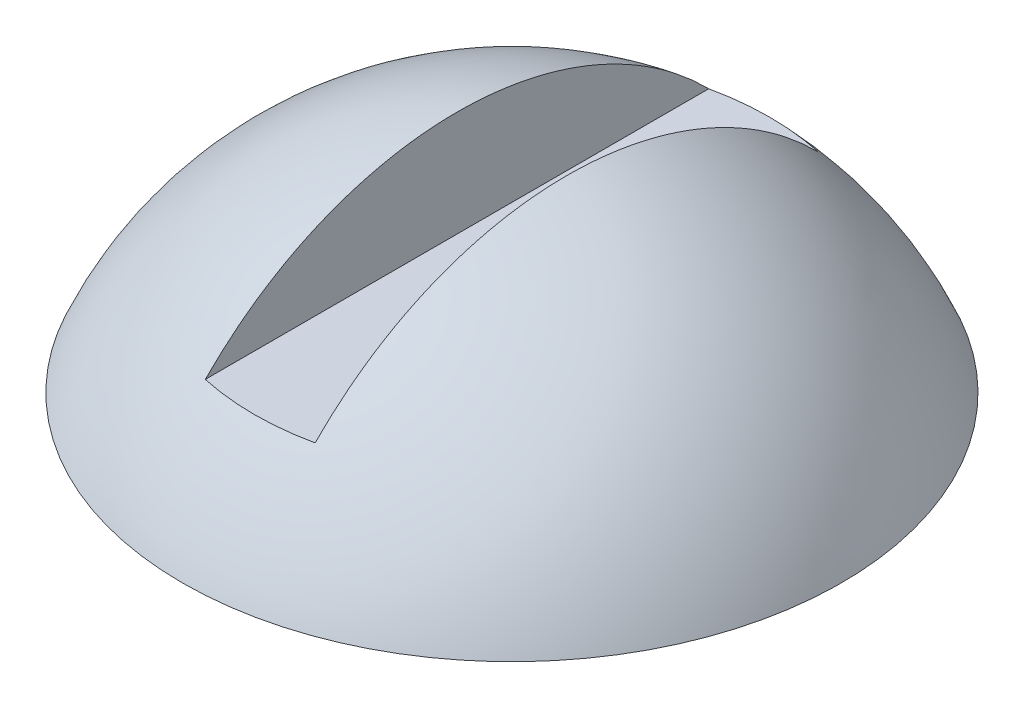
from build123d import *

# Parameters (mm, degrees)
CROQUIS2_W            = 1
CROQUIS2_H            = 6
CORTAR_EXTRUIR1_DEPTH = 1


with BuildPart() as part:
    # Croquis1 → Revolución1 (revolve)
    with BuildSketch(Plane(origin=(0, 0, 0), x_dir=(0, 0, -1), z_dir=(1, 0, 0))):
        with BuildLine():
            Line((-3, 0), (0, 0))
            Line((0, 0), (0, 2))
            ThreePointArc((0, 2), (-1.802775638, 1.454163457), (-3, 0))
        make_face()
    revolve(axis=Axis((0, 3.545719076, 0), (0, -1, 0)))

    # Croquis2 → Cortar-Extruir1 (cut)
    with BuildSketch(Plane(origin=(0, 2, 0), x_dir=(1, 0, 0), z_dir=(0, 1, 0))):
        Rectangle(CROQUIS2_W, CROQUIS2_H)
    extrude(amount=-CORTAR_EXTRUIR1_DEPTH, mode=Mode.SUBTRACT)


solid = part.part
